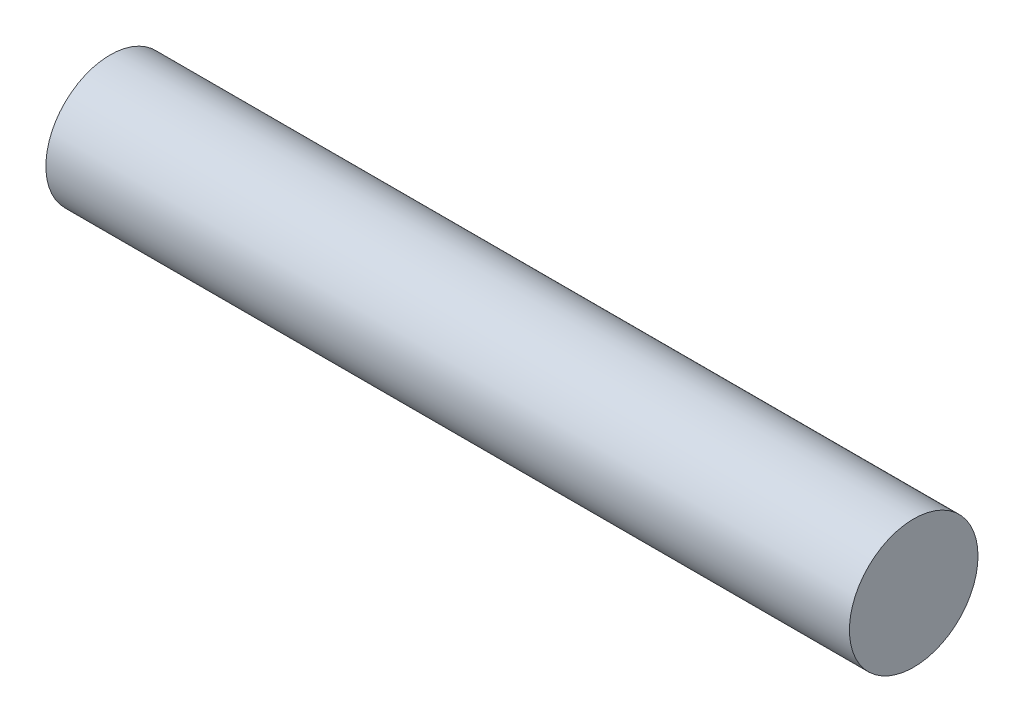
from build123d import *

# Parameters (mm, degrees)
SKETCH1_R           = 8
BOSS_EXTRUDE1_DEPTH = 100


with BuildPart() as part:
    # Sketch1 → Boss-Extrude1 (new body)
    with BuildSketch(Plane(origin=(0, 0, 0), x_dir=(0, 0, -1), z_dir=(1, 0, 0))):
        Circle(SKETCH1_R)
    extrude(amount=BOSS_EXTRUDE1_DEPTH)


solid = part.part
